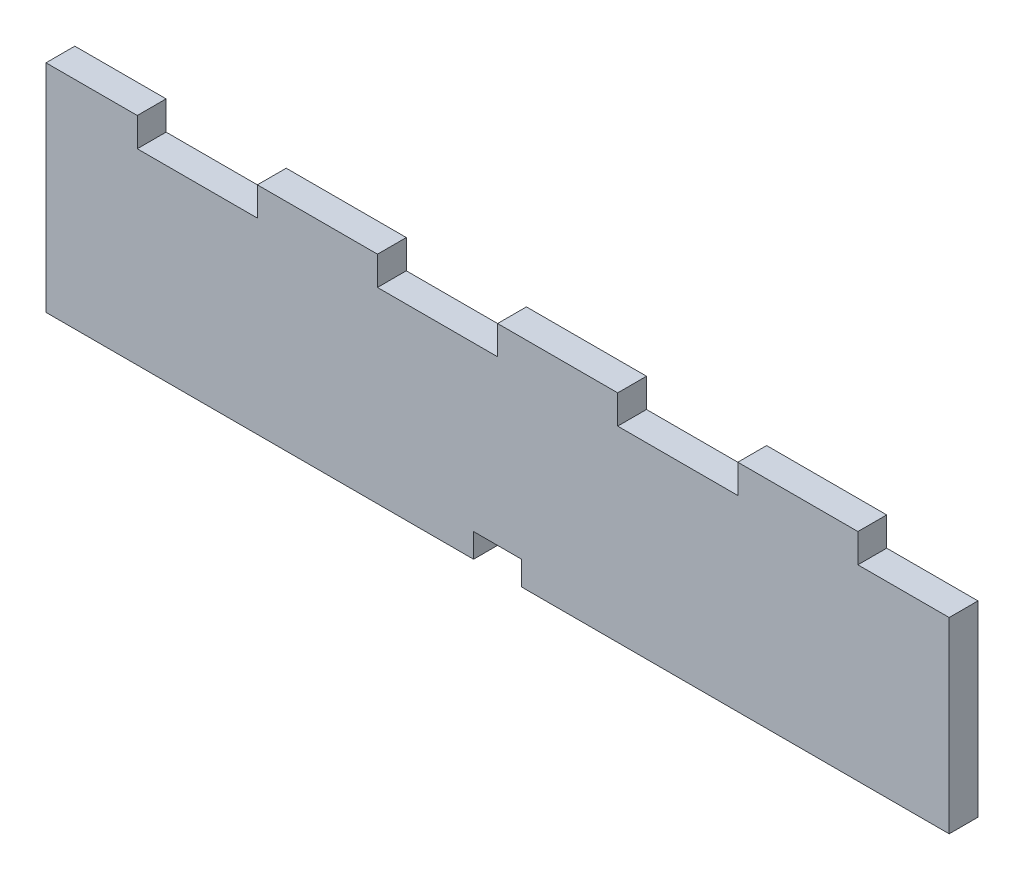
from build123d import *

# Parameters (mm, degrees)
RESSALTO_EXTRUS_O1_DEPTH = 6


with BuildPart() as part:
    # Esboço1 → Ressalto-extrusão1 (new body)
    with BuildSketch(Plane.XY):
        Polygon((0, 39), (0, 0), (89, 0), (89, 5), (94, 5), (99, 5), (99, 0), (188, 0), (188, 39.0000038), (169, 39.0000038), (169, 45.0000038), (144, 45.0000038), (144, 39.0000038), (119, 39.0000038), (119, 45.0000038), (94, 45.0000038), (94, 39.0000038), (69, 39.0000038), (69, 45.0000038), (44, 45.0000038), (44, 39.0000038), (19, 39.0000038), (19, 45), (0, 45), align=None)
    extrude(amount=RESSALTO_EXTRUS_O1_DEPTH)


solid = part.part
